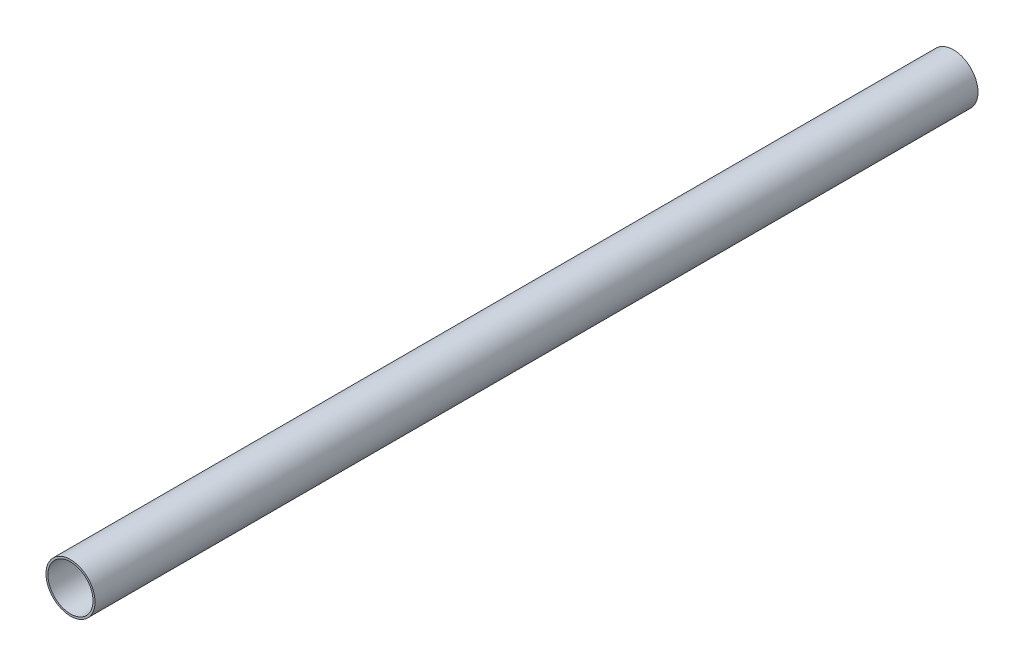
from build123d import *

# Parameters (mm, degrees)
SKETCH_1_R      = 50
SKETCH_1_R_2    = 46
EXTRUDE_1_DEPTH = 1800


with BuildPart() as part:
    # Эскиз1 → Бобышка-Вытянуть1 (new body)
    with BuildSketch(Plane.XY):
        Circle(SKETCH_1_R)
        Circle(SKETCH_1_R_2, mode=Mode.SUBTRACT)
    extrude(amount=EXTRUDE_1_DEPTH)


solid = part.part
